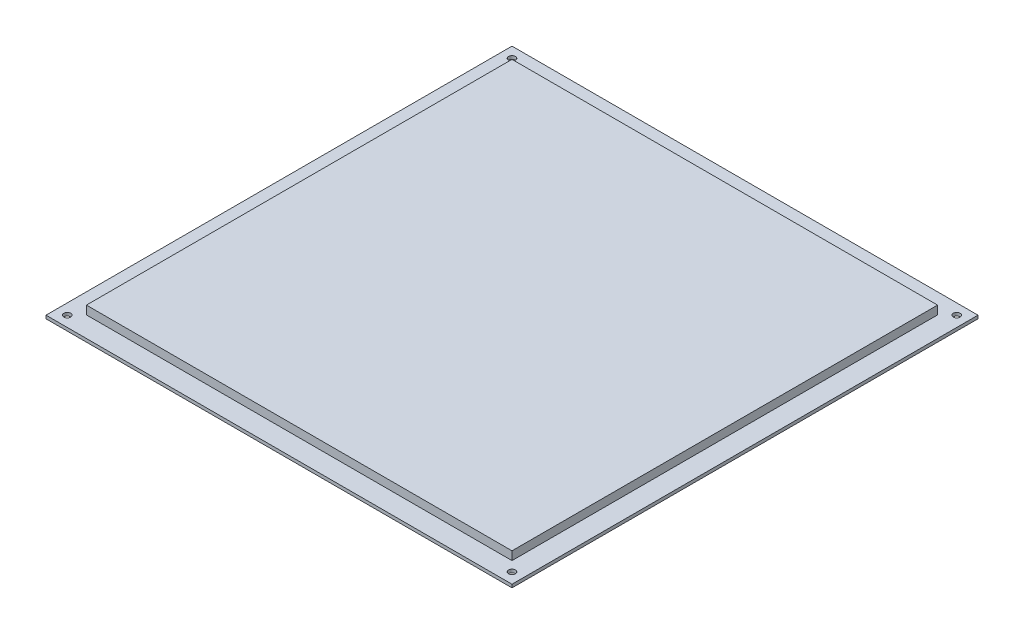
from build123d import *

# Parameters (mm, degrees)
SKETCH1_W            = 219
SKETCH1_H            = 219
BOSS_EXTRUDE1_DEPTH  = 1.5
M3_CLEARANCE_HOLE1_D = 3.2
SKETCH5_W            = 200
SKETCH5_H            = 200
BOSS_EXTRUDE2_DEPTH  = 4


with BuildPart() as part:
    # Sketch1 → Boss-Extrude1 (new body)
    with BuildSketch(Plane(origin=(0, 0, 0), x_dir=(1, 0, 0), z_dir=(0, 1, 0))):
        Rectangle(SKETCH1_W, SKETCH1_H)
    extrude(amount=BOSS_EXTRUDE1_DEPTH)

    # M3 Clearance Hole1 (through all)
    with Locations(Plane(origin=(0, 1.5, 0), x_dir=(1, 0, 0), z_dir=(0, 1, 0))):
        with Locations((-104.5, 104.5), (104.5, 104.5), (104.5, -104.5), (-104.5, -104.5)):
            Hole(M3_CLEARANCE_HOLE1_D / 2)


with BuildPart() as body_2:
    # Sketch5 → Boss-Extrude2 (new body)
    with BuildSketch(Plane(origin=(0, 1.6, 0), x_dir=(1, 0, 0), z_dir=(0, 1, 0))):
        Rectangle(SKETCH5_W, SKETCH5_H)
    extrude(amount=BOSS_EXTRUDE2_DEPTH)


solid = Compound([part.part, body_2.part])
